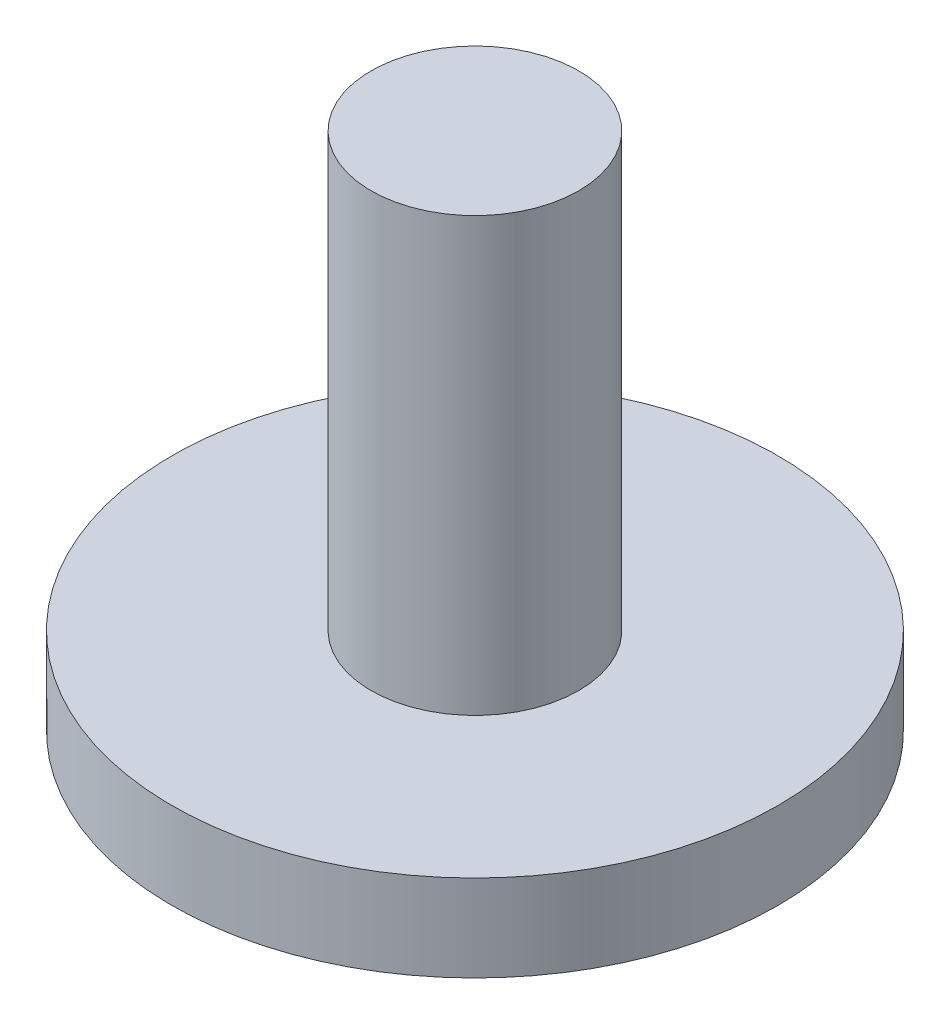
from build123d import *


with BuildPart() as part:
    # Sketch1 → Revolve1 (revolve)
    with BuildSketch(Plane.XY):
        Polygon((0, 6), (2.4, 6), (2.4, -4), (7, -4), (7, -6), (0, -6), align=None)
    revolve(axis=Axis((0, -404.38598492, 0), (0, 1, 0)))


solid = part.part
